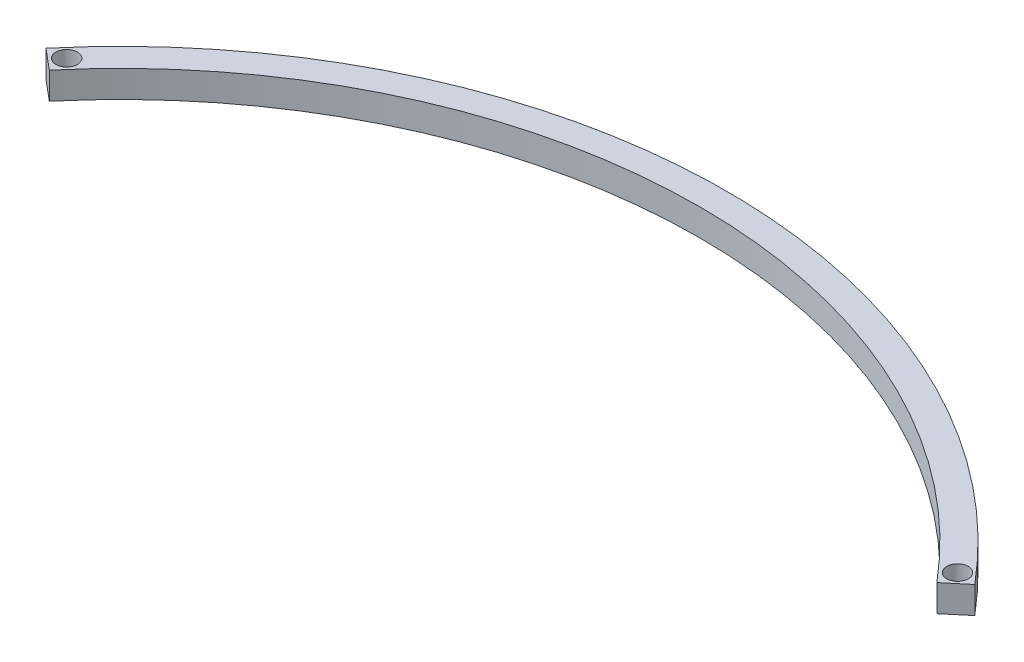
from build123d import *

# Parameters (mm, degrees)
SKETCH1_R           = 4
BOSS_EXTRUDE1_DEPTH = 5


with BuildPart() as part:
    # Sketch1 → Boss-Extrude1 (new body, symmetric)
    with BuildSketch(Plane(origin=(0, 0, 0), x_dir=(1, 0, 0), z_dir=(0, 1, 0))):
        with BuildLine():
            Line((-172.359999702, 144.627212179), (-164.699555271, 138.199336083))
            ThreePointArc((-164.699555271, 138.199336083), (0, 215), (164.699555271, 138.199336083))
            Line((164.699555271, 138.199336083), (172.359999702, 144.627212179))
            ThreePointArc((172.359999702, 144.627212179), (0, 225), (-172.359999702, 144.627212179))
        make_face()
        with Locations((-165.315839438, 145.243496347)):
            Circle(SKETCH1_R, mode=Mode.SUBTRACT)
        with Locations((165.315839438, 145.243496347)):
            Circle(SKETCH1_R, mode=Mode.SUBTRACT)
    extrude(amount=BOSS_EXTRUDE1_DEPTH, both=True)


solid = part.part
